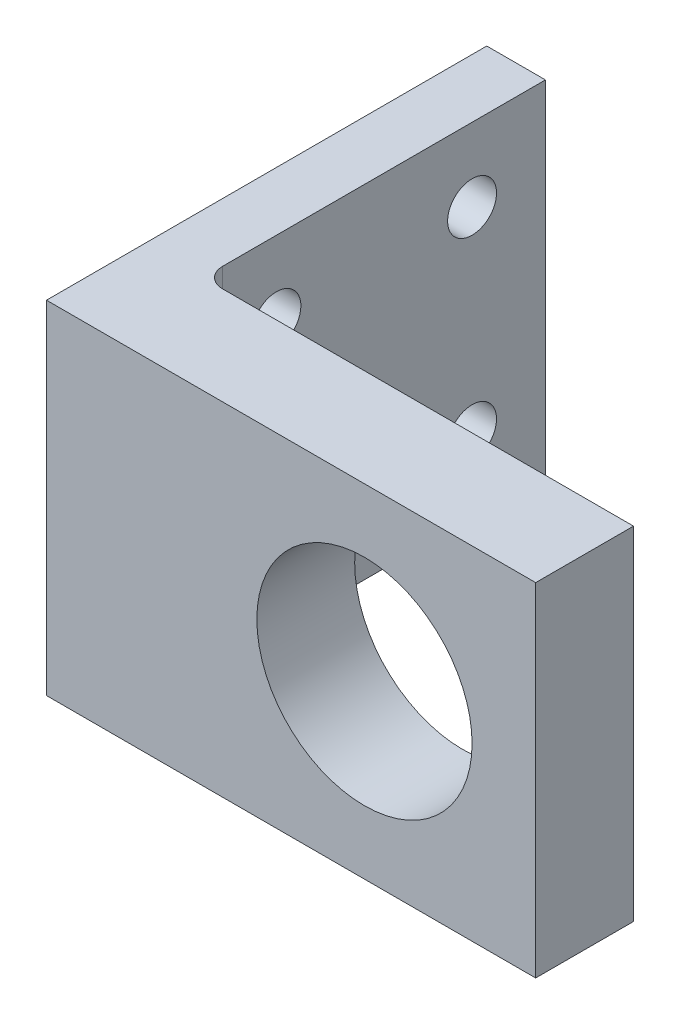
from build123d import *

# Parameters (mm, degrees)
SKETCH1_W           = 50
SKETCH1_H           = 35
SKETCH1_R           = 11
BOSS_EXTRUDE3_DEPTH = 10
BOSS_EXTRUDE6_DEPTH = 35
SKETCH9_R           = 2.5
CUT_EXTRUDE1_DEPTH  = 10
FILLET1_R           = 2


with BuildPart() as part:
    # Sketch1 → Boss-Extrude3 (new body)
    with BuildSketch(Plane.XY):
        with Locations((25, 17.5)):
            Rectangle(SKETCH1_W, SKETCH1_H)
        with Locations((32.5, 17.5)):
            Circle(SKETCH1_R, mode=Mode.SUBTRACT)
    extrude(amount=BOSS_EXTRUDE3_DEPTH)

    # Sketch8 → Boss-Extrude6 (add)
    with BuildSketch(Plane(origin=(0, 0, 0), x_dir=(-1, 0, 0), z_dir=(0, 0, -1))):
        Polygon((-6, 10.000000197), (-6, 0), (0, 0), (0, 10.000000197), (0, 25), (0, 35), (-6, 35), (-6, 25), align=None)
    extrude(amount=BOSS_EXTRUDE6_DEPTH)

    # Sketch9 → Cut-Extrude1 (cut)
    with BuildSketch(Plane(origin=(6, 0, 0), x_dir=(0, 0, -1), z_dir=(1, 0, 0))):
        with Locations((7.5, 27.5)):
            Circle(SKETCH9_R)
        with Locations((27.5, 27.5)):
            Circle(SKETCH9_R)
        with Locations((7.5, 7.5)):
            Circle(SKETCH9_R)
        with Locations((27.5, 7.5)):
            Circle(SKETCH9_R)
    extrude(amount=-CUT_EXTRUDE1_DEPTH, mode=Mode.SUBTRACT)

    # Fillet1
    fillet1_edges = [part.edges().sort_by_distance(p)[0] for p in [
        (6, 17.5, 0),
    ]]
    fillet(fillet1_edges, radius=FILLET1_R)


solid = part.part
